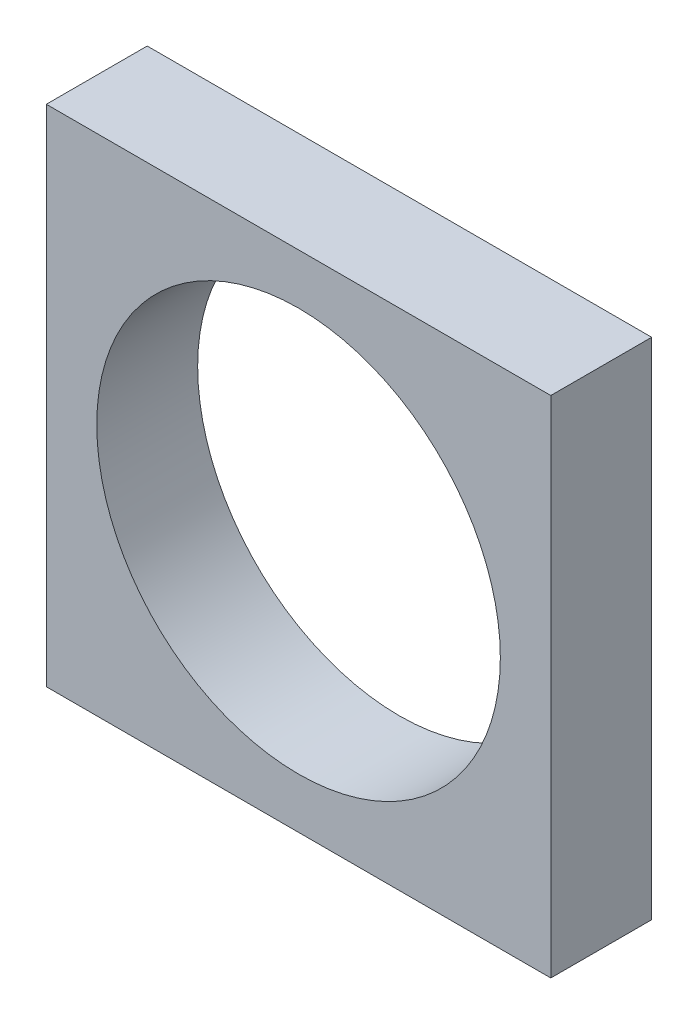
from build123d import *

# Parameters (mm, degrees)
SKETCH1_W           = 100
SKETCH1_H           = 100
BOSS_EXTRUDE1_DEPTH = 20
SKETCH2_R           = 40
CUT_EXTRUDE1_DEPTH  = 20


with BuildPart() as part:
    # Sketch1 → Boss-Extrude1 (new body)
    with BuildSketch(Plane.XY):
        Rectangle(SKETCH1_W, SKETCH1_H)
    extrude(amount=BOSS_EXTRUDE1_DEPTH)

    # Sketch2 → Cut-Extrude1 (cut)
    with BuildSketch(Plane.XY.offset(20)):
        Circle(SKETCH2_R)
    extrude(amount=-CUT_EXTRUDE1_DEPTH, mode=Mode.SUBTRACT)


solid = part.part
